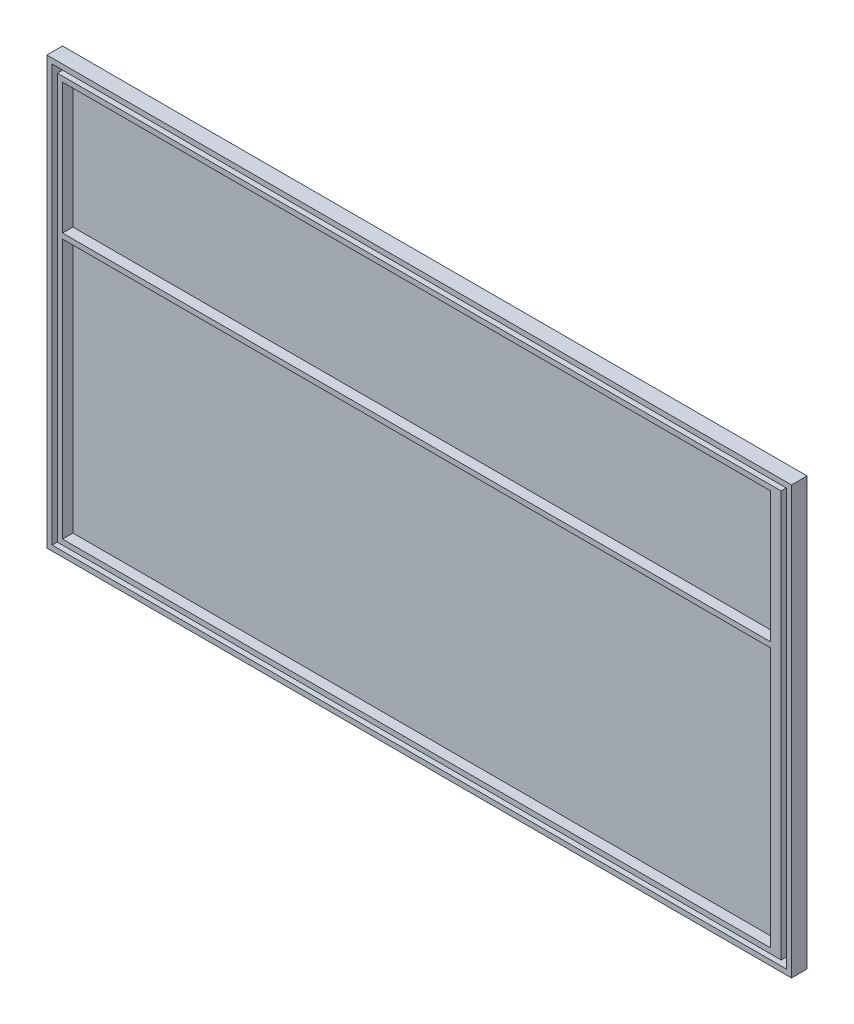
from build123d import *

# Parameters (mm, degrees)
CROQUIS1_W              = 143
CROQUIS1_H              = 82
SALIENTE_EXTRUIR1_DEPTH = 1
CROQUIS2_W              = 143
CROQUIS2_H              = 82
CROQUIS2_W_2            = 141
CROQUIS2_H_2            = 80
CROQUIS2_W_3            = 139
CROQUIS2_H_3            = 78
CROQUIS2_W_4            = 136
CROQUIS2_H_4            = 25.104148451
CROQUIS2_H_5            = 49.895851549
SALIENTE_EXTRUIR2_DEPTH = 2


with BuildPart() as part:
    # Croquis1 → Saliente-Extruir1 (new body)
    with BuildSketch(Plane.XY):
        with Locations((-99.522825922, 14.293939394)):
            Rectangle(CROQUIS1_W, CROQUIS1_H)
    extrude(amount=SALIENTE_EXTRUIR1_DEPTH)

    # Croquis2 → Saliente-Extruir2 (add)
    with BuildSketch(Plane.XY.offset(1)):
        with Locations((-99.522825922, 14.293939394)):
            Rectangle(CROQUIS2_W, CROQUIS2_H)
        with Locations((-99.522825922, 14.293939394)):
            Rectangle(CROQUIS2_W_2, CROQUIS2_H_2, mode=Mode.SUBTRACT)
        with Locations((-99.522825922, 14.293939394)):
            Rectangle(CROQUIS2_W_3, CROQUIS2_H_3)
        with Locations((-100.022825922, 39.741865169)):
            Rectangle(CROQUIS2_W_4, CROQUIS2_H_4, mode=Mode.SUBTRACT)
        with Locations((-100.022825922, 1.241865169)):
            Rectangle(CROQUIS2_W_4, CROQUIS2_H_5, mode=Mode.SUBTRACT)
    extrude(amount=SALIENTE_EXTRUIR2_DEPTH)


solid = part.part
